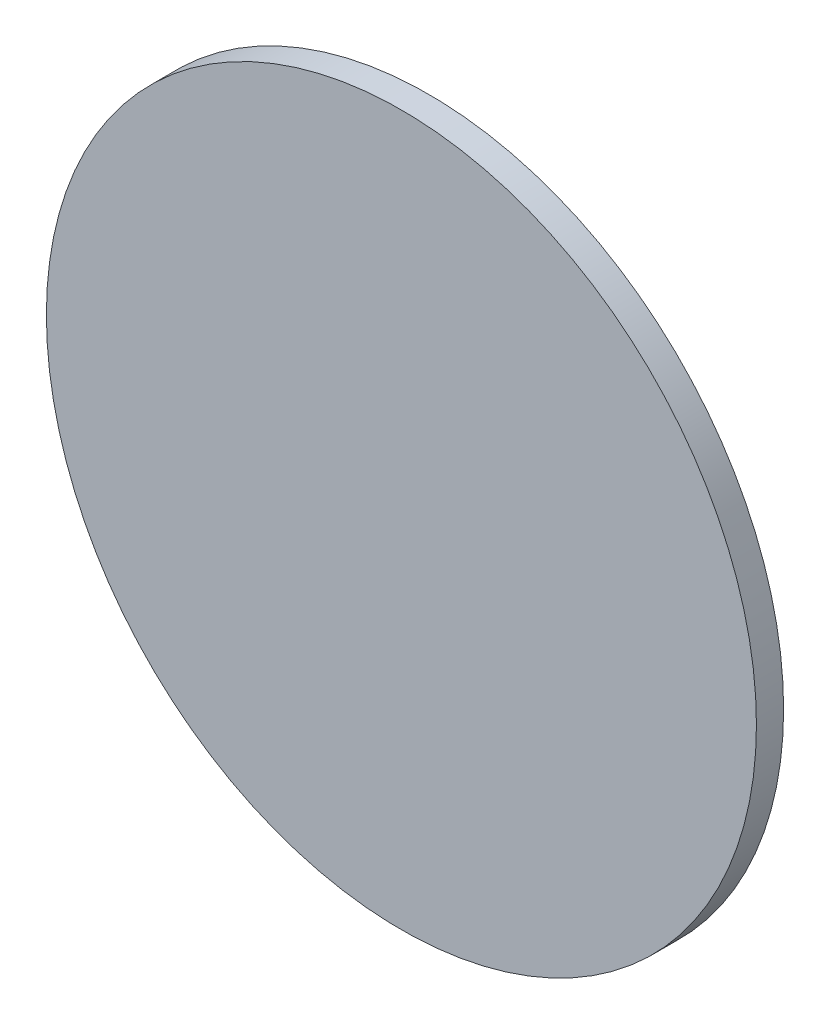
from build123d import *

# Parameters (mm, degrees)
SCHIZZO1_R                   = 7.5
ESTRUSIONE_ESTRUSIONE1_DEPTH = 0.574


with BuildPart() as part:
    # Schizzo1 → Estrusione-Estrusione1 (new body)
    with BuildSketch(Plane.XY):
        Circle(SCHIZZO1_R)
    extrude(amount=ESTRUSIONE_ESTRUSIONE1_DEPTH)


solid = part.part
